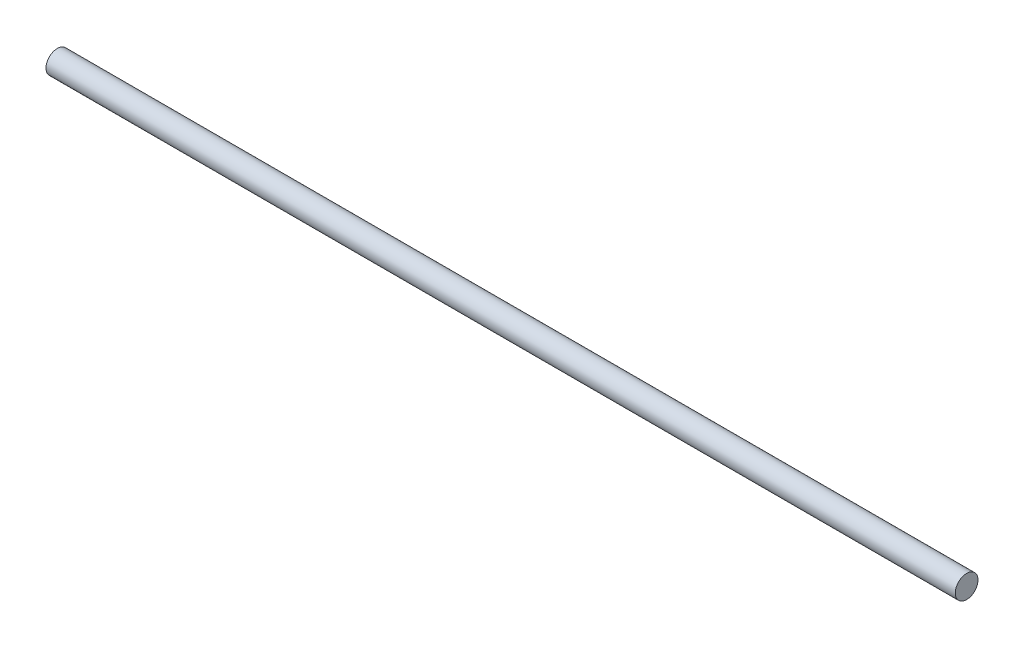
from build123d import *

# Parameters (mm, degrees)
SKETCH1_R           = 1.25
BOSS_EXTRUDE1_DEPTH = 100


with BuildPart() as part:
    # Sketch1 → Boss-Extrude1 (new body)
    with BuildSketch(Plane(origin=(0, 0, 0), x_dir=(0, 0, -1), z_dir=(1, 0, 0))):
        Circle(SKETCH1_R)
    extrude(amount=BOSS_EXTRUDE1_DEPTH)


solid = part.part
